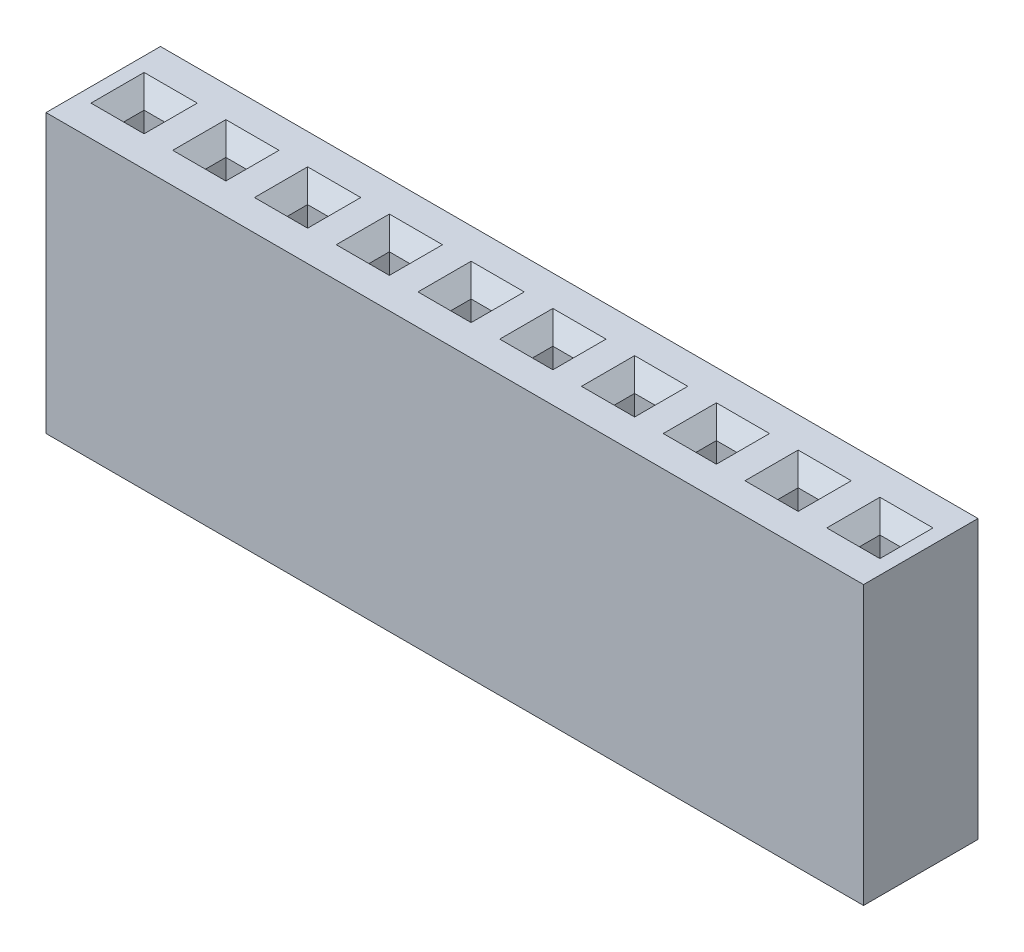
from build123d import *

# Parameters (mm, degrees)
SKETCH1_W                  = 25.4
SKETCH1_H                  = 3.556
BOSS_EXTRUDE1_DEPTH        = 8.636
SKETCH2_W                  = 0.635
SKETCH2_H                  = 0.635
CUT_EXTRUDE1_DEPTH         = 6.35
CHAMFER1_SIZE              = 0.508
LPATTERN1_COUNT            = 10
LPATTERN1_PITCH            = 2.54
CHAMFER1_OF_LPATTERN1_SIZE = 0.508


with BuildPart() as part:
    # Sketch1 → Boss-Extrude1 (new body)
    with BuildSketch(Plane(origin=(0, 0, 0), x_dir=(1, 0, 0), z_dir=(0, 1, 0))):
        with Locations((12.7, 1.778)):
            Rectangle(SKETCH1_W, SKETCH1_H)
    extrude(amount=BOSS_EXTRUDE1_DEPTH)

    # Sketch2 → Cut-Extrude1 (cut)
    with BuildSketch(Plane(origin=(0, 8.636, 0), x_dir=(1, 0, 0), z_dir=(0, 1, 0))):
        with Locations((1.27, 1.778)):
            Rectangle(SKETCH2_W, SKETCH2_H)
    cut_extrude1 = extrude(amount=-CUT_EXTRUDE1_DEPTH, mode=Mode.SUBTRACT)

    # Chamfer1
    chamfer1_edges = [part.edges().sort_by_distance(p)[0] for p in [
        (1.5875, 8.636, -1.778),
        (1.27, 8.636, -2.0955),
        (0.9525, 8.636, -1.778),
        (1.27, 8.636, -1.4605),
    ]]
    chamfer(chamfer1_edges, length=CHAMFER1_SIZE)

    # LPattern1: Cut-Extrude1 ×10
    with Locations(*[(i * LPATTERN1_PITCH, 0, 0) for i in range(1, LPATTERN1_COUNT)]):
        add(cut_extrude1, mode=Mode.SUBTRACT)

    # Chamfer1 of LPattern1
    chamfer1_of_lpattern1_edges = [part.edges().sort_by_distance(p)[0] for p in [
        (4.1275, 8.636, -1.778),
        (3.81, 8.636, -2.0955),
        (3.4925, 8.636, -1.778),
        (3.81, 8.636, -1.4605),
        (6.6675, 8.636, -1.778),
        (6.35, 8.636, -2.0955),
        (6.0325, 8.636, -1.778),
        (6.35, 8.636, -1.4605),
        (9.2075, 8.636, -1.778),
        (8.89, 8.636, -2.0955),
        (8.5725, 8.636, -1.778),
        (8.89, 8.636, -1.4605),
        (11.7475, 8.636, -1.778),
        (11.43, 8.636, -2.0955),
        (11.1125, 8.636, -1.778),
        (11.43, 8.636, -1.4605),
        (14.2875, 8.636, -1.778),
        (13.97, 8.636, -2.0955),
        (13.6525, 8.636, -1.778),
        (13.97, 8.636, -1.4605),
        (16.8275, 8.636, -1.778),
        (16.51, 8.636, -2.0955),
        (16.1925, 8.636, -1.778),
        (16.51, 8.636, -1.4605),
        (19.3675, 8.636, -1.778),
        (19.05, 8.636, -2.0955),
        (18.7325, 8.636, -1.778),
        (19.05, 8.636, -1.4605),
        (21.9075, 8.636, -1.778),
        (21.59, 8.636, -2.0955),
        (21.2725, 8.636, -1.778),
        (21.59, 8.636, -1.4605),
        (24.4475, 8.636, -1.778),
        (24.13, 8.636, -2.0955),
        (23.8125, 8.636, -1.778),
        (24.13, 8.636, -1.4605),
    ]]
    chamfer(chamfer1_of_lpattern1_edges, length=CHAMFER1_OF_LPATTERN1_SIZE)


solid = part.part
